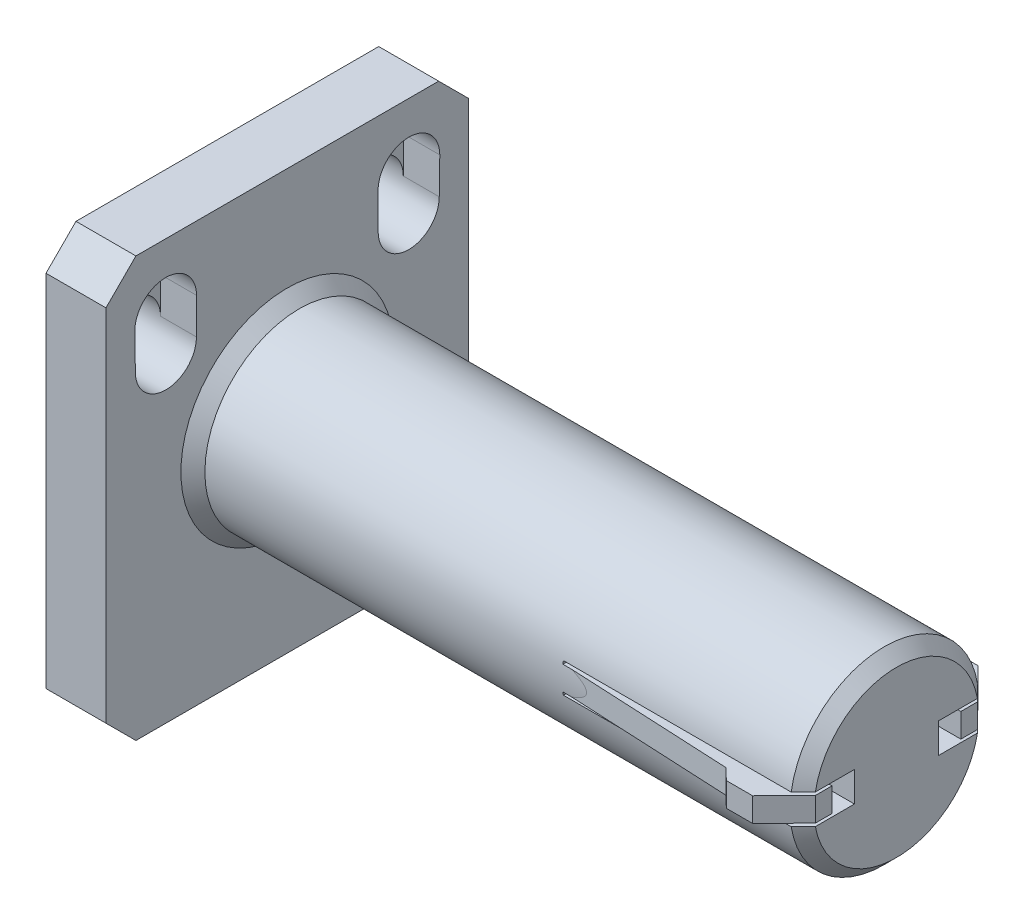
from build123d import *

# Parameters (mm, degrees)
SKETCH1_W            = 60.5
SKETCH1_H            = 70
BOSS_EXTRUDE1_DEPTH  = 10
SKETCH2_R            = 15.75
BOSS_EXTRUDE2_DEPTH  = 101.6
CUT_EXTRUDE1_DEPTH   = 40
SKETCH8_W            = 3.25
SKETCH8_H            = 5
CUT_EXTRUDE2_DEPTH   = 40
CHAMFER3_SIZE        = 2
BOSS_EXTRUDE9_DEPTH  = 4
BOSS_EXTRUDE10_DEPTH = 4
CHAMFER4_SIZE        = 5
CUT_EXTRUDE9_DEPTH   = 4
CHAMFER6_SIZE        = 2


with BuildPart() as part:
    # Sketch1 → Boss-Extrude1 (new body)
    with BuildSketch(Plane(origin=(0, 0, 0), x_dir=(0, 0, -1), z_dir=(1, 0, 0))):
        with Locations((0.23118778, -0.809157231)):
            Rectangle(SKETCH1_W, SKETCH1_H)
        with BuildLine():
            Line((-14.90655725, 23.440204594), (-14.924987971, 17.440316828))
            ThreePointArc((-14.924987971, 17.440316828), (-20.01881222, 12.34649258), (-25.112636468, 17.440316828))
            Line((-25.112636468, 17.440316828), (-25.204464795, 23.440204594))
            ThreePointArc((-25.204464795, 23.440204594), (-20.055511023, 28.589158366), (-14.90655725, 23.440204594))
        make_face(mode=Mode.SUBTRACT)
        with BuildLine():
            ThreePointArc((15.368932811, 23.440204594), (20.517886583, 28.589158366), (25.666840355, 23.440204594))
            Line((25.666840355, 23.440204594), (25.575012029, 17.440316828))
            ThreePointArc((25.575012029, 17.440316828), (20.48118778, 12.34649258), (15.387363532, 17.440316828))
            Line((15.387363532, 17.440316828), (15.368932811, 23.440204594))
        make_face(mode=Mode.SUBTRACT)
    extrude(amount=BOSS_EXTRUDE1_DEPTH)

    # Sketch2 → Boss-Extrude2 (add)
    with BuildSketch(Plane(origin=(10, 0, 0), x_dir=(0, 0, -1), z_dir=(1, 0, 0))):
        with Locations((0.23118778, -0.809157231)):
            Circle(SKETCH2_R)
    extrude(amount=BOSS_EXTRUDE2_DEPTH)

    # Sketch3 → Cut-Extrude1 (cut)
    with BuildSketch(Plane(origin=(111.6, 0, 0), x_dir=(0, 0, -1), z_dir=(1, 0, 0))):
        Polygon((-15.51881222, 1.190842769), (-10.51881222, 1.190842769), (-10.51881222, -2.809157231), (-15.51881222, -2.809157231), (-15.51881222, -3.309157231), (-10.01881222, -3.309157231), (-10.01881222, 1.690842769), (-15.51881222, 1.690842769), align=None)
        Polygon((15.98118778, -2.809157231), (15.98118778, -3.309157231), (10.48118778, -3.309157231), (10.48118778, 1.690842769), (15.98118778, 1.690842769), (15.98118778, 1.190842769), (10.98118778, 1.190842769), (10.98118778, -2.809157231), align=None)
    extrude(amount=-CUT_EXTRUDE1_DEPTH, mode=Mode.SUBTRACT)

    # Sketch8 → Cut-Extrude2 (cut)
    with BuildSketch(Plane(origin=(111.6, 0, 0), x_dir=(0, 0, -1), z_dir=(1, 0, 0))):
        with Locations((8.85618778, -0.809157231)):
            Rectangle(SKETCH8_W, SKETCH8_H)
        with Locations((-8.39381222, -0.809157231)):
            Rectangle(SKETCH8_W, SKETCH8_H)
    extrude(amount=-CUT_EXTRUDE2_DEPTH, mode=Mode.SUBTRACT)

    # Chamfer3
    chamfer3_edges = [part.edges().sort_by_distance(p)[0] for p in [
        (111.6, -16.559157231, -0.23118778),
        (111.6, 14.940842769, -0.23118778),
    ]]
    chamfer(chamfer3_edges, length=CHAMFER3_SIZE)

    # Sketch19 → Boss-Extrude9 (add)
    with BuildSketch(Plane.ZY):
        with BuildLine():
            Line((-25.666840355, 23.440204594), (-25.575012029, 17.440316828))
            ThreePointArc((-25.575012029, 17.440316828), (-25.569608823, 17.67487337), (-25.553410667, 17.908932306))
            ThreePointArc((-25.553410667, 17.908932306), (-24.917258091, 19.94397928), (-23.503874553, 21.540366846))
            Line((-23.503874553, 21.540366846), (-23.503874553, 23.440204594))
            ThreePointArc((-23.503874553, 23.440204594), (-20.517886583, 26.426192563), (-17.531898613, 23.440204594))
            Line((-17.531898613, 23.440204594), (-17.531898613, 21.593476936))
            ThreePointArc((-17.531898613, 21.593476936), (-15.9551406, 19.777396716), (-15.387363532, 17.440316828))
            Line((-15.387363532, 17.440316828), (-15.368932811, 23.440204594))
            ThreePointArc((-15.368932811, 23.440204594), (-20.517886583, 28.589158366), (-25.666840355, 23.440204594))
        make_face()
        with BuildLine():
            ThreePointArc((25.204464795, 23.440204594), (20.055511023, 28.589158366), (14.90655725, 23.440204594))
            Line((14.90655725, 23.440204594), (14.924987971, 17.440316828))
            ThreePointArc((14.924987971, 17.440316828), (15.49276504, 19.777396716), (17.069523053, 21.593476936))
            Line((17.069523053, 21.593476936), (17.069523053, 23.440204594))
            ThreePointArc((17.069523053, 23.440204594), (20.055511023, 26.426192563), (23.041498992, 23.440204594))
            Line((23.041498992, 23.440204594), (23.041498992, 21.540366846))
            ThreePointArc((23.041498992, 21.540366846), (24.454882531, 19.94397928), (25.091035106, 17.908932306))
            ThreePointArc((25.091035106, 17.908932306), (25.107233262, 17.67487337), (25.112636468, 17.440316828))
            Line((25.112636468, 17.440316828), (25.204464795, 23.440204594))
        make_face()
    extrude(amount=-BOSS_EXTRUDE9_DEPTH)

    # Sketch23 → Boss-Extrude10 (add)
    with BuildSketch(Plane(origin=(0, 1.190842769, 0), x_dir=(1, 0, 0), z_dir=(0, 1, 0))):
        Polygon((71.6, 15.78150932), (100.084633461, 17.181034874), (102.038578597, 19.029077367), (111.6, 19.029077367), (111.6, 15.78150932), align=None)
        Polygon((100.084633461, -16.718659314), (102.038578597, -18.566701807), (111.6, -18.566701807), (111.6, -15.31913376), (71.6, -15.31913376), align=None)
    extrude(amount=-BOSS_EXTRUDE10_DEPTH)

    # Chamfer4
    chamfer4_edges = [part.edges().sort_by_distance(p)[0] for p in [
        (5, -35.809157231, 30.01881222),
        (5, 34.190842769, 30.01881222),
        (5, 34.190842769, -30.48118778),
        (5, -35.809157231, -30.48118778),
    ]]
    chamfer(chamfer4_edges, length=CHAMFER4_SIZE)

    # Sketch28 → Cut-Extrude9 (cut)
    with BuildSketch(Plane(origin=(0, 1.190842769, 0), x_dir=(1, 0, 0), z_dir=(0, 1, 0))):
        Polygon((111.6, 13.752005063), (105.070544586, 20.392137095), (111.6, 20.392137095), align=None)
        Polygon((111.6, -19.929761535), (111.6, -13.289629503), (105.070544586, -19.929761535), align=None)
    extrude(amount=-CUT_EXTRUDE9_DEPTH, mode=Mode.SUBTRACT)

    # Chamfer6
    chamfer6_edges = [part.edges().sort_by_distance(p)[0] for p in [
        (10, -0.809157231, 15.51881222),
    ]]
    chamfer(chamfer6_edges, length=CHAMFER6_SIZE)


solid = part.part
